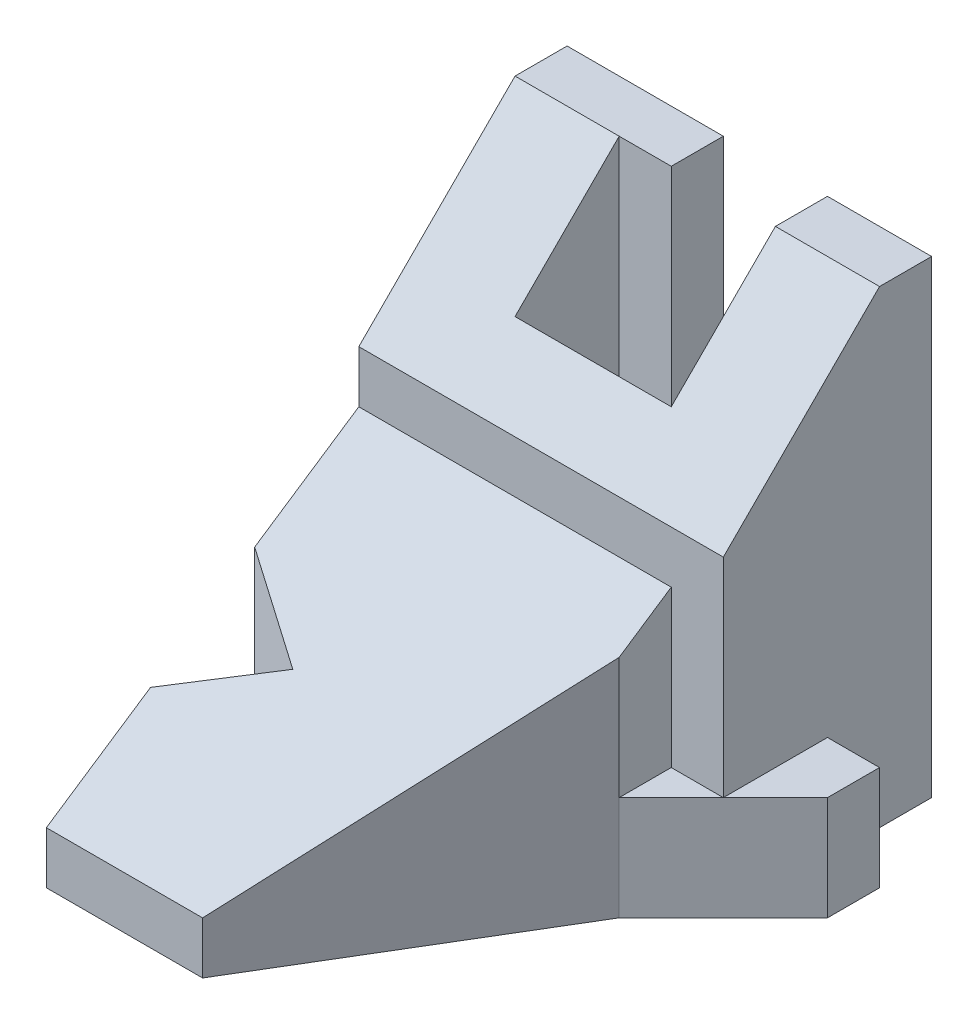
from build123d import *

# Parameters (mm, degrees)
SKETCH1_W           = 35
SKETCH1_H           = 45
BOSS_EXTRUDE2_DEPTH = 20
CUT_EXTRUDE1_DEPTH  = 46
CUT_EXTRUDE2_DEPTH  = 36
SKETCH5_W           = 10
SKETCH5_H           = 10
BOSS_EXTRUDE3_DEPTH = 5
CUT_EXTRUDE3_DEPTH  = 11
SKETCH7_W           = 30
SKETCH7_H           = 25
BOSS_EXTRUDE4_DEPTH = 30
SKETCH8_W           = 5
SKETCH8_H           = 10
BOSS_EXTRUDE5_DEPTH = 5
CUT_EXTRUDE4_DEPTH  = 11
SKETCH11_W          = 5
SKETCH11_H          = 45
BOSS_EXTRUDE6_DEPTH = 5
BOSS_EXTRUDE7_DEPTH = 5
CUT_EXTRUDE7_DEPTH  = 26
CUT_EXTRUDE8_DEPTH  = 26
CUT_EXTRUDE11_DEPTH = 41


with BuildPart() as part:
    # Sketch1 → Boss-Extrude2 (new body)
    with BuildSketch(Plane.XY):
        Rectangle(SKETCH1_W, SKETCH1_H)
    extrude(amount=BOSS_EXTRUDE2_DEPTH)

    # Sketch3 → Cut-Extrude1 (cut, through all)
    with BuildSketch(Plane(origin=(0, 22.5, 0), x_dir=(1, 0, 0), z_dir=(0, 1, 0))):
        Polygon((7.5, 0), (7.5, -15), (-12.5, -15), (-12.5, -5), (-7.5, -5), (-7.5, 0), align=None)
    extrude(amount=-CUT_EXTRUDE1_DEPTH, mode=Mode.SUBTRACT)

    # Sketch4 → Cut-Extrude2 (cut, through all)
    with BuildSketch(Plane(origin=(17.5, 0, 0), x_dir=(0, 0, -1), z_dir=(1, 0, 0))):
        Polygon((-5, 22.5), (-20, 7.5), (-20, 22.5), align=None)
    extrude(amount=-CUT_EXTRUDE2_DEPTH, mode=Mode.SUBTRACT)

    # Sketch5 → Boss-Extrude3 (add)
    with BuildSketch(Plane(origin=(17.5, 0, 0), x_dir=(0, 0, -1), z_dir=(1, 0, 0))):
        with Locations((-15, -17.5)):
            Rectangle(SKETCH5_W, SKETCH5_H)
    extrude(amount=BOSS_EXTRUDE3_DEPTH)

    # Sketch6 → Cut-Extrude3 (cut, through all)
    with BuildSketch(Plane(origin=(0, -12.5, 0), x_dir=(1, 0, 0), z_dir=(0, 1, 0))):
        Polygon((17.5, -20), (22.5, -15), (22.5, -20), align=None)
    extrude(amount=-CUT_EXTRUDE3_DEPTH, mode=Mode.SUBTRACT)

    # Sketch7 → Boss-Extrude4 (add)
    with BuildSketch(Plane.XY.offset(20)):
        with Locations((-2.5, -10)):
            Rectangle(SKETCH7_W, SKETCH7_H)
    extrude(amount=BOSS_EXTRUDE4_DEPTH)

    # Sketch8 → Boss-Extrude5 (add)
    with BuildSketch(Plane.XY.offset(20)):
        with Locations((15, -17.5)):
            Rectangle(SKETCH8_W, SKETCH8_H)
    extrude(amount=BOSS_EXTRUDE5_DEPTH)

    # Sketch9 → Cut-Extrude4 (cut, through all)
    with BuildSketch(Plane(origin=(0, -12.5, 0), x_dir=(1, 0, 0), z_dir=(0, 1, 0))):
        Polygon((17.5, -20), (12.5, -25), (17.5, -25), align=None)
    extrude(amount=-CUT_EXTRUDE4_DEPTH, mode=Mode.SUBTRACT)

    # Sketch11 → Boss-Extrude6 (add)
    with BuildSketch(Plane(origin=(-7.5, 0, 0), x_dir=(0, 0, -1), z_dir=(1, 0, 0))):
        with Locations((-2.5, 0)):
            Rectangle(SKETCH11_W, SKETCH11_H)
    extrude(amount=BOSS_EXTRUDE6_DEPTH)

    # Sketch12 → Boss-Extrude7 (add)
    with BuildSketch(Plane(origin=(-12.5, 0, 0), x_dir=(0, 0, -1), z_dir=(1, 0, 0))):
        Polygon((-5, 22.5), (-5, -22.5), (-15, -22.5), (-15, 12.5), align=None)
    extrude(amount=BOSS_EXTRUDE7_DEPTH)

    # Sketch13 → Cut-Extrude7 (cut, through all)
    with BuildSketch(Plane(origin=(0, 2.5, 0), x_dir=(1, 0, 0), z_dir=(0, 1, 0))):
        Polygon((12.5, -25), (-2.5, -50), (12.5, -50), align=None)
    extrude(amount=-CUT_EXTRUDE7_DEPTH, mode=Mode.SUBTRACT)

    # Sketch14 → Cut-Extrude8 (cut, through all)
    with BuildSketch(Plane(origin=(0, 2.5, 0), x_dir=(1, 0, 0), z_dir=(0, 1, 0))):
        Polygon((-17.5, -30), (-8.839745962, -35), (-17.5, -40), align=None)
    extrude(amount=-CUT_EXTRUDE8_DEPTH, mode=Mode.SUBTRACT)

    # Sketch15 → Cut-Extrude11 (cut, through all)
    with BuildSketch(Plane(origin=(-17.5, 0, 0), x_dir=(0, 0, -1), z_dir=(1, 0, 0))):
        Polygon((-20, 2.5), (-50, -17.5), (-50, 2.5), align=None)
    extrude(amount=CUT_EXTRUDE11_DEPTH, mode=Mode.SUBTRACT)


solid = part.part
